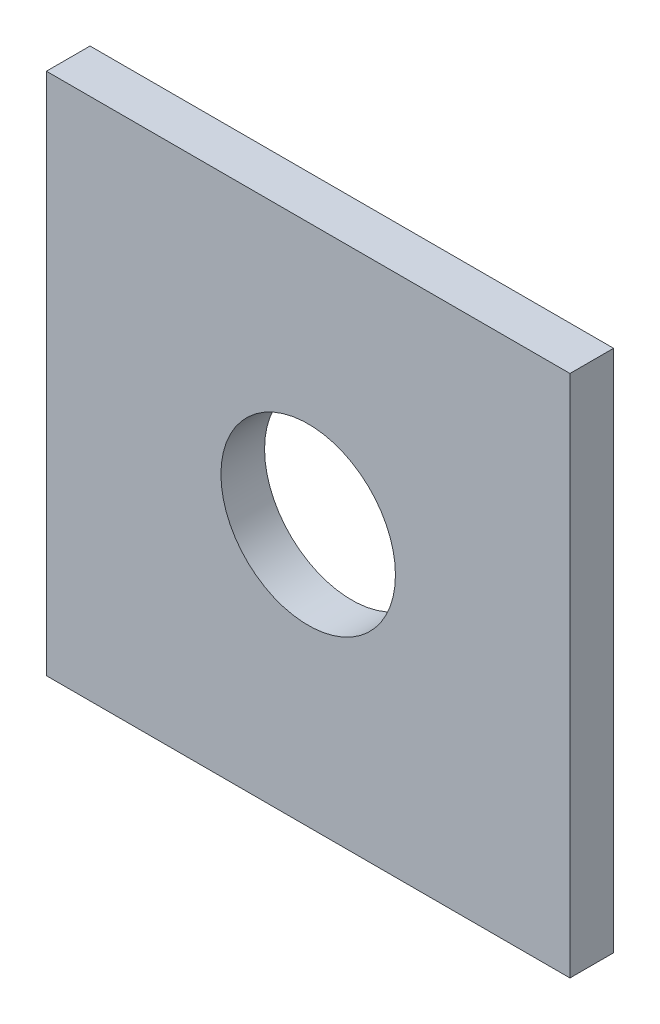
from build123d import *

# Parameters (mm, degrees)
SKETCH1_W           = 152.4
SKETCH1_H           = 152.4
BOSS_EXTRUDE1_DEPTH = 12.7
SKETCH2_R           = 25.4
CUT_EXTRUDE1_DEPTH  = 12.7


with BuildPart() as part:
    # Sketch1 → Boss-Extrude1 (new body)
    with BuildSketch(Plane.XY):
        with Locations((76.2, 76.2)):
            Rectangle(SKETCH1_W, SKETCH1_H)
    extrude(amount=BOSS_EXTRUDE1_DEPTH)

    # Sketch2 → Cut-Extrude1 (cut)
    with BuildSketch(Plane(origin=(0, 0, 0), x_dir=(-1, 0, 0), z_dir=(0, 0, -1))):
        with Locations((-76.2, 76.2)):
            Circle(SKETCH2_R)
    extrude(amount=-CUT_EXTRUDE1_DEPTH, mode=Mode.SUBTRACT)


solid = part.part
